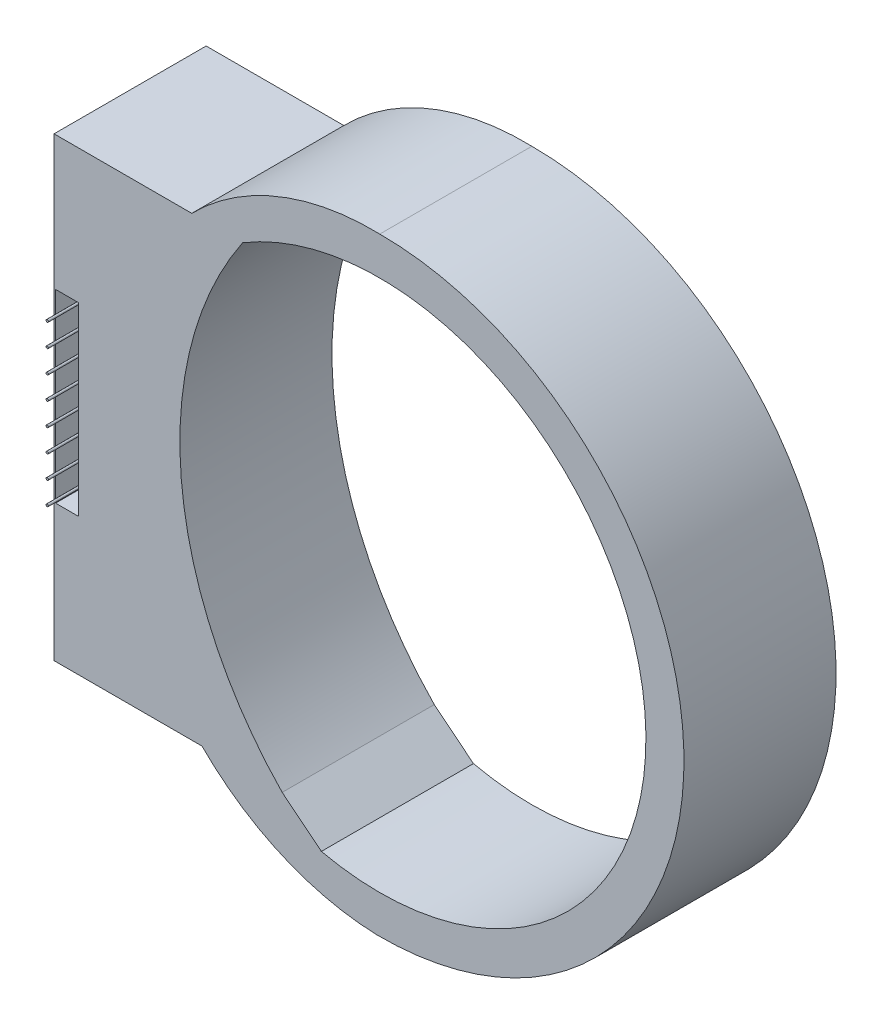
from build123d import *

# Parameters (mm, degrees)
BOSS_EXTRUDE1_DEPTH = 25.4
SKETCH2_W           = 3.81
SKETCH2_H           = 30.913886478
CUT_EXTRUDE1_DEPTH  = 24.638
SKETCH3_R           = 0.1905
BOSS_EXTRUDE2_DEPTH = 27.94


with BuildPart() as part:
    # Sketch1 → Boss-Extrude1 (new body)
    with BuildSketch(Plane(origin=(0, 0, 0), x_dir=(0, 1, 0), z_dir=(0, 0, 1))):
        with BuildLine():
            Line((38.1, 31.396083107), (38.1, 54.3969813))
            Line((38.1, 54.3969813), (-38.1, 54.3969813))
            Line((-38.1, 54.3969813), (-38.1, 29.686927473))
            ThreePointArc((-38.1, 29.686927473), (-47.228063928, 16.31611269), (-50.79728762, 0.524948031))
            ThreePointArc((-50.79728762, 0.524948031), (-0.262477519, -50.799321901), (50.8, 0))
            ThreePointArc((50.8, 0), (47.722223419, 17.021685566), (38.1, 31.396083107))
        make_face()
        with BuildLine():
            Line((-38.1, 16.2969813), (-43.366277143, 9.755434728))
            ThreePointArc((-43.366277143, 9.755434728), (7.077931126, -43.882859877), (38.1, 22.895250599))
            ThreePointArc((38.1, 22.895250599), (-1.174082446, 33.154986969), (-38.1, 16.2969813))
        make_face(mode=Mode.SUBTRACT)
    extrude(amount=BOSS_EXTRUDE1_DEPTH)

    # Sketch2 → Cut-Extrude1 (cut)
    with BuildSketch(Plane.XY.offset(25.4)):
        with Locations((-52.2379813, 0.268816404)):
            Rectangle(SKETCH2_W, SKETCH2_H)
    extrude(amount=-CUT_EXTRUDE1_DEPTH, mode=Mode.SUBTRACT)

    # Sketch3 → Boss-Extrude2 (add)
    with BuildSketch(Plane.XY.offset(0.762)):
        with Locations((-52.2379813, -12.905010915)):
            Circle(SKETCH3_R)
        with Locations((-52.2379813, -9.095010915)):
            Circle(SKETCH3_R)
        with Locations((-52.2379813, -5.285010915)):
            Circle(SKETCH3_R)
        with Locations((-52.2379813, -1.475010915)):
            Circle(SKETCH3_R)
        with Locations((-52.2379813, 2.334989085)):
            Circle(SKETCH3_R)
        with Locations((-52.2379813, 6.144989085)):
            Circle(SKETCH3_R)
        with Locations((-52.2379813, 9.954989085)):
            Circle(SKETCH3_R)
        with Locations((-52.2379813, 13.764989085)):
            Circle(SKETCH3_R)
    extrude(amount=BOSS_EXTRUDE2_DEPTH)


solid = part.part
